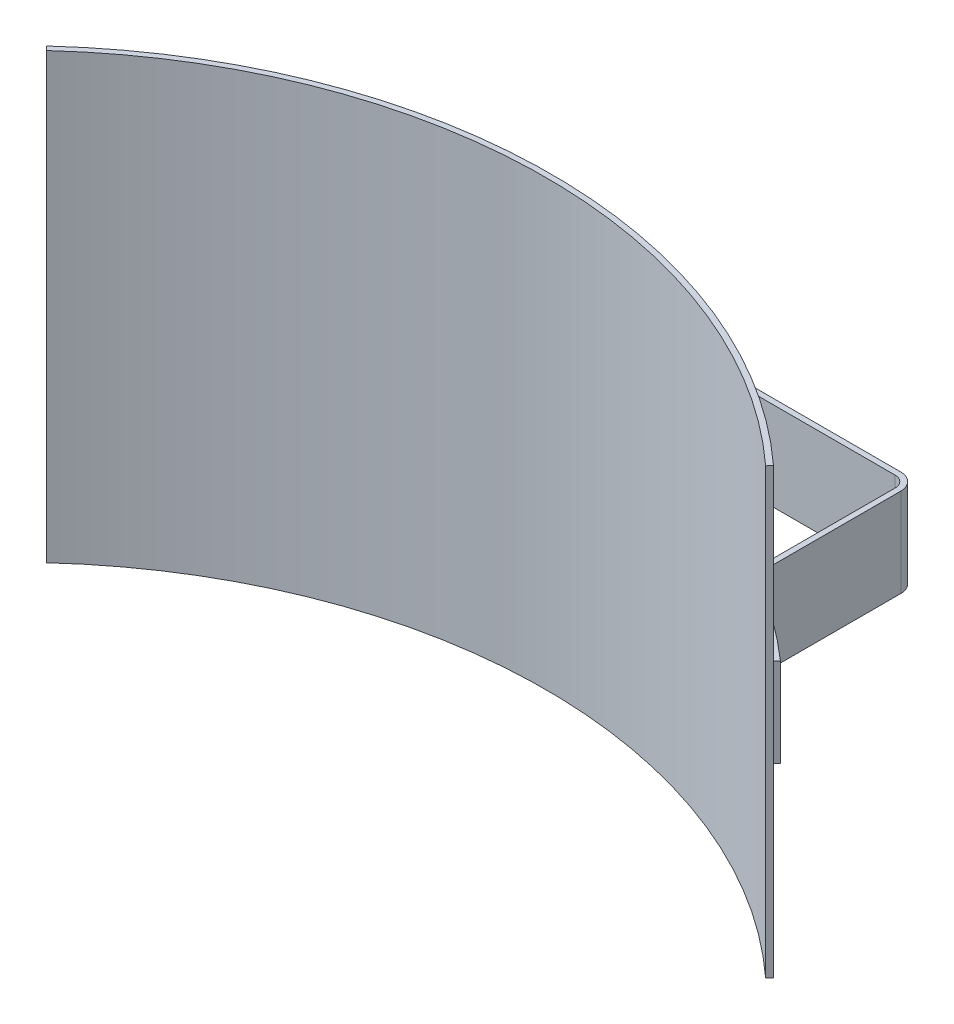
from build123d import *

# Parameters (mm, degrees)
BOSS_EXTRUDE1_DEPTH = 63.5
BOSS_EXTRUDE2_DEPTH = 12.7


with BuildPart() as part:
    # Sketch1 → Boss-Extrude1 (new body, symmetric)
    with BuildSketch(Plane(origin=(0, 0, 0), x_dir=(1, 0, 0), z_dir=(0, 1, 0))):
        with BuildLine():
            Line((104.032447095, 113.531493902), (102.959947641, 112.36106613))
            ThreePointArc((102.959947641, 112.36106613), (0, 152.4), (-102.959947641, 112.36106613))
            Line((-102.959947641, 112.36106613), (-104.032447095, 113.531493902))
            ThreePointArc((-104.032447095, 113.531493902), (0, 153.9875), (104.032447095, 113.531493902))
        make_face()
    extrude(amount=BOSS_EXTRUDE1_DEPTH, both=True)

    # Sketch2 → Boss-Extrude2 (add, symmetric)
    with BuildSketch(Plane(origin=(0, 0, 0), x_dir=(1, 0, 0), z_dir=(0, 1, 0))):
        with BuildLine():
            Line((73.025, 179.3875), (-73.025, 179.3875))
            ThreePointArc((-73.025, 179.3875), (-75.27006403, 178.45756403), (-76.2, 176.2125))
            Line((-76.2, 176.2125), (-76.2, 135.64534928))
            ThreePointArc((-76.2, 135.64534928), (-76.620744225, 134.065887306), (-77.771464646, 132.905039193))
            ThreePointArc((-77.771464646, 132.905039193), (-90.09671873, 124.878867028), (-101.6, 115.713396615))
            Line((-101.6, 115.713396615), (-102.64742268, 116.90631823))
            ThreePointArc((-102.64742268, 116.90631823), (-91.025550882, 126.166278029), (-78.573232323, 134.275194237))
            ThreePointArc((-78.573232323, 134.275194237), (-77.997872113, 134.855618293), (-77.7875, 135.64534928))
            Line((-77.7875, 135.64534928), (-77.7875, 176.2125))
            ThreePointArc((-77.7875, 176.2125), (-76.392596045, 179.580096045), (-73.025, 180.975))
            Line((-73.025, 180.975), (73.025, 180.975))
            ThreePointArc((73.025, 180.975), (76.392596045, 179.580096045), (77.7875, 176.2125))
            Line((77.7875, 176.2125), (77.7875, 135.64534928))
            ThreePointArc((77.7875, 135.64534928), (77.997872113, 134.855618293), (78.573232323, 134.275194237))
            ThreePointArc((78.573232323, 134.275194237), (91.025550882, 126.166278029), (102.64742268, 116.90631823))
            Line((102.64742268, 116.90631823), (101.6, 115.713396615))
            ThreePointArc((101.6, 115.713396615), (90.09671873, 124.878867028), (77.771464646, 132.905039193))
            ThreePointArc((77.771464646, 132.905039193), (76.620744225, 134.065887306), (76.2, 135.64534928))
            Line((76.2, 135.64534928), (76.2, 176.2125))
            ThreePointArc((76.2, 176.2125), (75.27006403, 178.45756403), (73.025, 179.3875))
        make_face()
    extrude(amount=BOSS_EXTRUDE2_DEPTH, both=True)


solid = part.part
